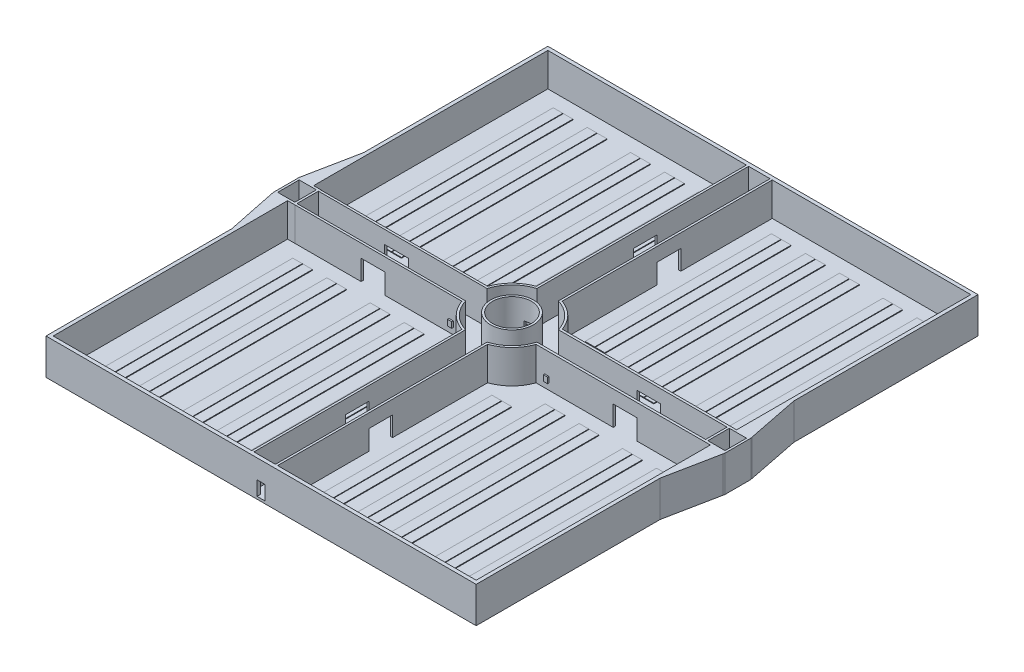
from build123d import *

# Parameters (mm, degrees)
SKETCH2_W                 = 60000
SKETCH2_H                 = 70000
BOSS_EXTRUDE1_DEPTH       = 350
SKETCH3_R                 = 3000
CUT_EXTRUDE1_DEPTH        = 1
CUT_EXTRUDE1_DEPTH_BACK   = 351
BOSS_EXTRUDE2_DEPTH       = 4650
CUT_EXTRUDE2_START        = -31801
CUT_EXTRUDE2_DEPTH        = 60002
CUT_EXTRUDE3_START        = -36801
CUT_EXTRUDE3_DEPTH        = 70002
SKETCH9_W                 = 60000
SKETCH9_H                 = 70000
SKETCH9_W_2               = 59000
SKETCH9_H_2               = 69000
BOSS_EXTRUDE3_DEPTH       = 4650
CUT_EXTRUDE4_DEPTH        = 1
CUT_EXTRUDE4_DEPTH_BACK   = 70001
SKETCH12_W                = 1337.685506768
SKETCH12_H                = 28664.780813437
SKETCH12_W_2              = 1337.314493232
BOSS_EXTRUDE5_DEPTH       = 100
SKETCH13_R                = 3000
SKETCH13_R_2              = 2700
BOSS_EXTRUDE6_DEPTH       = 5000
BOSS_EXTRUDE6_DEPTH_BACK  = 1000
CUT_EXTRUDE6_DEPTH        = 60000
SKETCH16_W                = 1340
SKETCH16_H                = 26000
BOSS_EXTRUDE7_DEPTH       = 100
MIRROR4_COPY_1_SKETCH_W   = 1337.685506768
MIRROR4_COPY_1_SKETCH_H   = 28664.780813437
MIRROR4_COPY_1_SKETCH_W_2 = 1337.314493232
MIRROR4_COPY_1_DEPTH      = 100
BOSS_EXTRUDE12_START      = -350
BOSS_EXTRUDE12_DEPTH      = 5000
SKETCH26_W                = 600
SKETCH26_H                = 800
BOSS_EXTRUDE14_DEPTH      = 220
MIRROR15_COPY_1_SKETCH_W  = 600
MIRROR15_COPY_1_SKETCH_H  = 800
MIRROR15_COPY_1_DEPTH     = 220
MIRROR15_COPY_2_SKETCH_W  = 600
MIRROR15_COPY_2_SKETCH_H  = 800
MIRROR15_COPY_2_DEPTH     = 220
SKETCH20_W                = 2400
SKETCH20_H                = 3000
CUT_EXTRUDE7_DEPTH        = 4650
CUT_EXTRUDE9_DEPTH        = 400


with BuildPart() as part:
    # Sketch2 → Boss-Extrude1 (new body)
    with BuildSketch(Plane(origin=(0, 0, 0), x_dir=(1, 0, 0), z_dir=(0, 1, 0))):
        Rectangle(SKETCH2_W, SKETCH2_H)
    extrude(amount=BOSS_EXTRUDE1_DEPTH)

    # Sketch3 → Cut-Extrude1 (cut, two sides)
    with BuildSketch(Plane(origin=(0, 350, 0), x_dir=(1, 0, 0), z_dir=(0, 1, 0))) as cut_extrude1_sk:
        Circle(SKETCH3_R)
    extrude(amount=CUT_EXTRUDE1_DEPTH, mode=Mode.SUBTRACT)
    extrude(cut_extrude1_sk.sketch, amount=-CUT_EXTRUDE1_DEPTH_BACK, mode=Mode.SUBTRACT)

    # Sketch4 → Boss-Extrude2 (add)
    with BuildSketch(Plane(origin=(0, 350, 0), x_dir=(1, 0, 0), z_dir=(0, 1, 0))):
        with BuildLine():
            Line((-30000, 1495.711965542), (-30000, 1795.711965542))
            Line((-30000, 1795.711965542), (-5198.597747163, 1795.711965542))
            ThreePointArc((-5198.597747163, 1795.711965542), (-3890.6911404, 3887.48279096), (-1800, 5197.114584075))
            Line((-1800, 5197.114584075), (-1800, 35000))
            Line((-1800, 35000), (-1500, 35000))
            Line((-1500, 35000), (-1500, 4978.955713802))
            ThreePointArc((-1500, 4978.955713802), (-3678.538071342, 3675.371771357), (-4980.245547775, 1495.711965542))
            Line((-4980.245547775, 1495.711965542), (-5292.716289027, 1495.711965542))
            Line((-5292.716289027, 1495.711965542), (-30000, 1495.711965542))
        make_face()
        with BuildLine():
            Line((-30000, -1500), (-4978.955713802, -1500))
            ThreePointArc((-4978.955713802, -1500), (-3676.95526217, -3676.95526217), (-1500, -4978.955713802))
            Line((-1500, -4978.955713802), (-1500, -35000))
            Line((-1500, -35000), (-1800, -35000))
            Line((-1800, -35000), (-1800, -5197.114584075))
            ThreePointArc((-1800, -5197.114584075), (-3889.087296526, -3889.087296526), (-5197.114584075, -1800))
            Line((-5197.114584075, -1800), (-30000, -1800))
            Line((-30000, -1800), (-30000, -1500))
        make_face()
        with BuildLine():
            Line((30000, 1495.711965542), (30000, 1830.438373126))
            Line((30000, 1830.438373126), (5186.472342758, 1830.438373126))
            ThreePointArc((5186.472342758, 1830.438373126), (3877.670193089, 3900.470981001), (1800, 5197.114584075))
            Line((1800, 5197.114584075), (1800, 35000))
            Line((1800, 35000), (1500, 35000))
            Line((1500, 35000), (1500, 4978.955713802))
            ThreePointArc((1500, 4978.955713802), (3678.538071342, 3675.371771357), (4980.245547775, 1495.711965542))
            Line((4980.245547775, 1495.711965542), (30000, 1495.711965542))
        make_face()
        with BuildLine():
            Line((4978.955713802, -1500), (30000, -1500))
            Line((30000, -1500), (30000, -1800))
            Line((30000, -1800), (5197.114584075, -1800))
            ThreePointArc((5197.114584075, -1800), (3889.087296526, -3889.087296526), (1800, -5197.114584075))
            Line((1800, -5197.114584075), (1800, -35000))
            Line((1800, -35000), (1500, -35000))
            Line((1500, -35000), (1500, -4978.955713802))
            ThreePointArc((1500, -4978.955713802), (3676.95526217, -3676.95526217), (4978.955713802, -1500))
        make_face()
    extrude(amount=BOSS_EXTRUDE2_DEPTH)

    # Sketch6 → Cut-Extrude2 (cut)
    with BuildSketch(Plane.ZY.offset(1800).offset(CUT_EXTRUDE2_START)):
        Polygon((20098.557292037, 350), (21748.557292037, 350), (21748.557292037, 3100), (20098.557292037, 3100), (18448.557292037, 3100), (18448.557292037, 350), align=None)
    cut_extrude2 = extrude(amount=CUT_EXTRUDE2_DEPTH, mode=Mode.SUBTRACT)

    # Mirror1: Cut-Extrude2 across plane
    add(cut_extrude2.mirror(Plane(origin=(0, 0, 0), x_dir=(1, 0, 0), z_dir=(0, 0, -1))), mode=Mode.SUBTRACT)

    # Sketch7 → Cut-Extrude3 (cut)
    with BuildSketch(Plane.XY.offset(1800).offset(CUT_EXTRUDE3_START)):
        Polygon((-17598.557292037, 350), (-15948.557292037, 350), (-15948.557292037, 3170.045761237), (-17598.557292037, 3170.045761237), (-19248.557292037, 3170.045761237), (-19248.557292037, 350), align=None)
    cut_extrude3 = extrude(amount=CUT_EXTRUDE3_DEPTH, mode=Mode.SUBTRACT)

    # Mirror2: Cut-Extrude3 across plane
    add(cut_extrude3.mirror(Plane.ZY), mode=Mode.SUBTRACT)

    # Sketch9 → Boss-Extrude3 (add)
    with BuildSketch(Plane(origin=(0, 350, 0), x_dir=(1, 0, 0), z_dir=(0, 1, 0))):
        Rectangle(SKETCH9_W, SKETCH9_H)
        Rectangle(SKETCH9_W_2, SKETCH9_H_2, mode=Mode.SUBTRACT)
    extrude(amount=BOSS_EXTRUDE3_DEPTH)

    # Sketch11 → Cut-Extrude4 (cut, two sides)
    with BuildSketch(Plane.XY.offset(35000)) as cut_extrude4_sk:
        Polygon((550, 2345.832597599), (550, 2000), (550, 350), (-550, 350), (-550, 2000), (-550, 2345.832597599), align=None)
    extrude(amount=CUT_EXTRUDE4_DEPTH, mode=Mode.SUBTRACT)
    extrude(cut_extrude4_sk.sketch, amount=-CUT_EXTRUDE4_DEPTH_BACK, mode=Mode.SUBTRACT)

    # Sketch12 → Boss-Extrude5 (add)
    with BuildSketch(Plane(origin=(0, 350, 0), x_dir=(1, 0, 0), z_dir=(0, 1, 0))):
        with Locations((21329.714538653, 18162.828779845)):
            Rectangle(SKETCH12_W, SKETCH12_H)
        with Locations((19917.214538653, 18162.828779845)):
            Rectangle(SKETCH12_W_2, SKETCH12_H)
        Polygon((25411.057292037, 3830.438373126), (25411.057292037, 32495.219186563), (26748.557292037, 32495.219186563), (26748.557292037, 18184.780561825), (26748.557292037, 3830.438373126), align=None)
        Polygon((25336.057292037, 3830.438373126), (25336.057292037, 32495.219186563), (25160, 32495.219186563), (25090, 32495.219186563), (23998.557292037, 32495.219186563), (23998.557292037, 18165.219186563), (23998.557292037, 3830.438373126), (25090, 3830.438373126), (25102.109097724, 3830.438373126), (25160, 3830.438373126), align=None)
    boss_extrude5 = extrude(amount=BOSS_EXTRUDE5_DEPTH)

    # Mirror3: Boss-Extrude5 across plane
    add(boss_extrude5.mirror(Plane.ZY.offset(-17598.557292037)))

    # Sketch13 → Boss-Extrude6 (add, two sides)
    with BuildSketch(Plane(origin=(0, 350, 0), x_dir=(1, 0, 0), z_dir=(0, 1, 0))) as boss_extrude6_sk:
        Circle(SKETCH13_R)
        Circle(SKETCH13_R_2, mode=Mode.SUBTRACT)
    extrude(amount=BOSS_EXTRUDE6_DEPTH)
    extrude(boss_extrude6_sk.sketch, amount=-BOSS_EXTRUDE6_DEPTH_BACK)

    # Sketch15 → Cut-Extrude6 (cut)
    with BuildSketch(Plane(origin=(0, 0, 34500), x_dir=(-1, 0, 0), z_dir=(0, 0, -1))):
        Polygon((0, 350), (900, 350), (900, 2345.832597599), (900, 2600), (0, 2600), (-900, 2600), (-900, 350), align=None)
    extrude(amount=CUT_EXTRUDE6_DEPTH, mode=Mode.SUBTRACT)

    # Sketch16 → Boss-Extrude7 (add)
    with BuildSketch(Plane(origin=(0, 350, 0), x_dir=(1, 0, 0), z_dir=(0, 1, 0))):
        with Locations((5778.557292037, 19495.219186563)):
            Rectangle(SKETCH16_W, SKETCH16_H)
        with Locations((4363.557292037, 19495.219186563)):
            Rectangle(SKETCH16_W, SKETCH16_H)
    boss_extrude7 = extrude(amount=BOSS_EXTRUDE7_DEPTH)

    # Mirror4: Boss-Extrude7, Boss-Extrude5 across plane
    add(boss_extrude7.mirror(Plane.ZY))
    add(boss_extrude5.mirror(Plane.ZY))

    # Mirror4 copy 1 sketch → Mirror4 copy 1 (add)
    with BuildSketch(Plane(origin=(-35197.114584075, 350, 0), x_dir=(1, 0, 0), z_dir=(0, 1, 0))):
        with Locations((21329.714538653, 18162.828779845)):
            Rectangle(MIRROR4_COPY_1_SKETCH_W, MIRROR4_COPY_1_SKETCH_H)
        with Locations((19917.214538653, 18162.828779845)):
            Rectangle(MIRROR4_COPY_1_SKETCH_W_2, MIRROR4_COPY_1_SKETCH_H)
        Polygon((25411.057292037, 3830.438373126), (25411.057292037, 32495.219186563), (26748.557292037, 32495.219186563), (26748.557292037, 18184.780561825), (26748.557292037, 3830.438373126), align=None)
        Polygon((25336.057292037, 3830.438373126), (25336.057292037, 32495.219186563), (25160, 32495.219186563), (25090, 32495.219186563), (23998.557292037, 32495.219186563), (23998.557292037, 18165.219186563), (23998.557292037, 3830.438373126), (25090, 3830.438373126), (25102.109097724, 3830.438373126), (25160, 3830.438373126), align=None)
    extrude(amount=MIRROR4_COPY_1_DEPTH)

    # Sketch18 → Boss-Extrude12 (add)
    with BuildSketch(Plane(origin=(0, 350, 0), x_dir=(1, 0, 0), z_dir=(0, 1, 0)).offset(BOSS_EXTRUDE12_START)):
        Polygon((28500, -1500), (28500, 1495.711965542), (28500, 1795.711965542), (28500, 1830.438373126), (29500, 1830.438373126), (29500, 11830.438373126), (31500, 1795.711965542), (31500, 1495.711965542), (31500, -1500), (31500, -1804.092700607), (29500, -11500), (29500, -1801.364233536), (28500, -1800), align=None)
    boss_extrude12 = extrude(amount=BOSS_EXTRUDE12_DEPTH)

    # Sketch26 → Boss-Extrude14 (add)
    with BuildSketch(Plane.XY.offset(1800)):
        with Locations((-6694.701361114, 1630.664480551)):
            Rectangle(SKETCH26_W, SKETCH26_H)
    boss_extrude14 = extrude(amount=BOSS_EXTRUDE14_DEPTH)

    # Mirror9: part across plane


with BuildPart() as part_1:
    add(part.part)
    add(part.part.mirror(Plane(origin=(0, 0, 0), x_dir=(1, 0, 0), z_dir=(0, 0, -1))))

    # Mirror14: Boss-Extrude14 across plane
    add(boss_extrude14.mirror(Plane.ZY))

    # Mirror15 copy 1 sketch → Mirror15 copy 1 (add)
    with BuildSketch(Plane(origin=(0, 0, -1800), x_dir=(-1, 0, 0), z_dir=(0, 0, -1))):
        with Locations((-6694.701361114, 1630.664480551)):
            Rectangle(MIRROR15_COPY_1_SKETCH_W, MIRROR15_COPY_1_SKETCH_H)
    extrude(amount=MIRROR15_COPY_1_DEPTH)

    # Mirror15 copy 2 sketch → Mirror15 copy 2 (add)
    with BuildSketch(Plane(origin=(0, 0, -1800), x_dir=(1, 0, 0), z_dir=(0, 0, -1))):
        with Locations((-6694.701361114, -1630.664480551)):
            Rectangle(MIRROR15_COPY_2_SKETCH_W, MIRROR15_COPY_2_SKETCH_H)
    extrude(amount=MIRROR15_COPY_2_DEPTH)

    # Sketch20 → Cut-Extrude7 (cut)
    with BuildSketch(Plane(origin=(0, 5000, 0), x_dir=(1, 0, 0), z_dir=(0, 1, 0))):
        with Locations((30000, 13.172836259)):
            Rectangle(SKETCH20_W, SKETCH20_H)
    cut_extrude7 = extrude(amount=-CUT_EXTRUDE7_DEPTH, mode=Mode.SUBTRACT)

    # Mirror16: Boss-Extrude12, Cut-Extrude7 across plane
    add(boss_extrude12.mirror(Plane.ZY))
    add(cut_extrude7.mirror(Plane.ZY), mode=Mode.SUBTRACT)

    # Sketch27 → Cut-Extrude9 (cut)
    with BuildSketch(Plane.ZY.offset(-28500)):
        Polygon((0, 350), (600, 350), (600, 2650), (0, 2650), (-600, 2650), (-600, 373.78125369), (-600, 350), align=None)
    cut_extrude9 = extrude(amount=-CUT_EXTRUDE9_DEPTH, mode=Mode.SUBTRACT)

    # Mirror17: Cut-Extrude9 across plane
    add(cut_extrude9.mirror(Plane.ZY), mode=Mode.SUBTRACT)


solid = part_1.part
